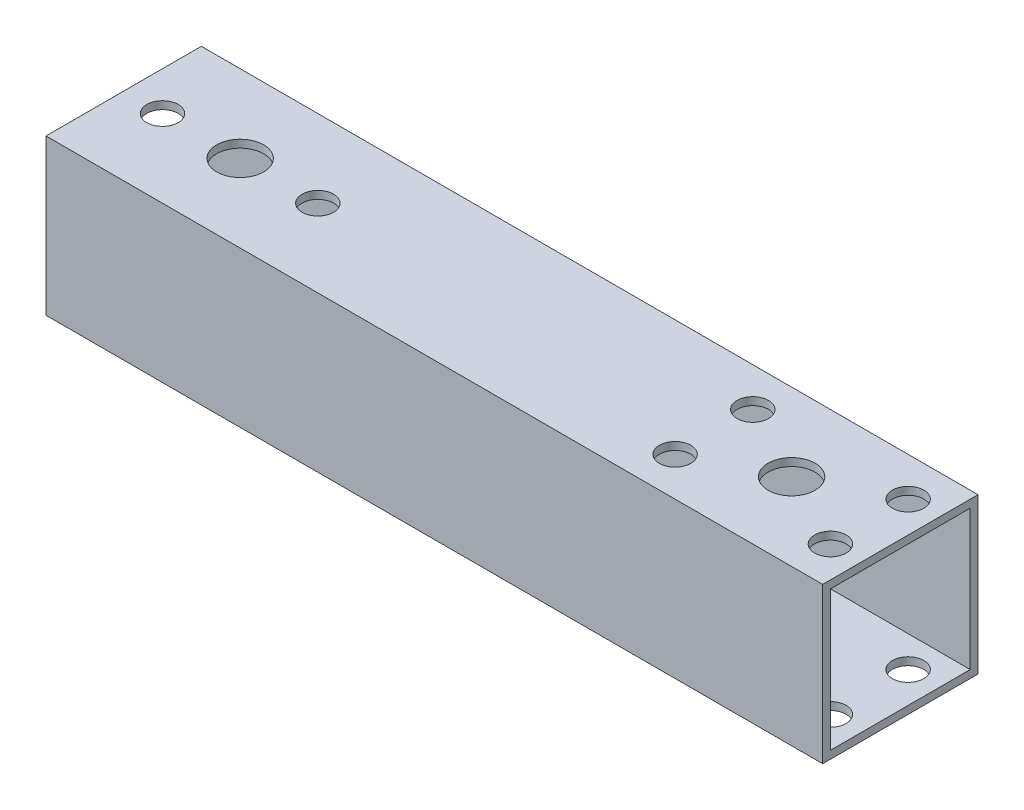
from build123d import *

# Parameters (mm, degrees)
SKETCH_1_W          = 20
SKETCH_1_H          = 20
SKETCH_1_W_2        = 18
SKETCH_1_H_2        = 18
EXTRUDE_1_DEPTH     = 50
SKETCH_2_R          = 2.025
SKETCH_2_R_2        = 3.025
CUT_EXTRUDE_1_DEPTH = 40


with BuildPart() as part:
    # 草图1 → 凸台-拉伸1 (new body, symmetric)
    with BuildSketch(Plane(origin=(0, 0, 0), x_dir=(0, 0, -1), z_dir=(1, 0, 0))):
        Rectangle(SKETCH_1_W, SKETCH_1_H)
        Rectangle(SKETCH_1_W_2, SKETCH_1_H_2, mode=Mode.SUBTRACT)
    extrude(amount=EXTRUDE_1_DEPTH, both=True)

    # 草图2 → 切除-拉伸1 (cut)
    with BuildSketch(Plane(origin=(0, 10, 0), x_dir=(1, 0, 0), z_dir=(0, 1, 0))):
        with Locations((26, 5)):
            Circle(SKETCH_2_R)
        with Locations((46, 5)):
            Circle(SKETCH_2_R)
        with Locations((46, -5)):
            Circle(SKETCH_2_R)
        with Locations((26, -5)):
            Circle(SKETCH_2_R)
        with Locations((36, 0)):
            Circle(SKETCH_2_R_2)
        with Locations((-45, 0)):
            Circle(SKETCH_2_R)
        with Locations((-25, 0)):
            Circle(SKETCH_2_R)
        with Locations((-35, 0)):
            Circle(SKETCH_2_R_2)
    extrude(amount=-CUT_EXTRUDE_1_DEPTH, mode=Mode.SUBTRACT)


solid = part.part
